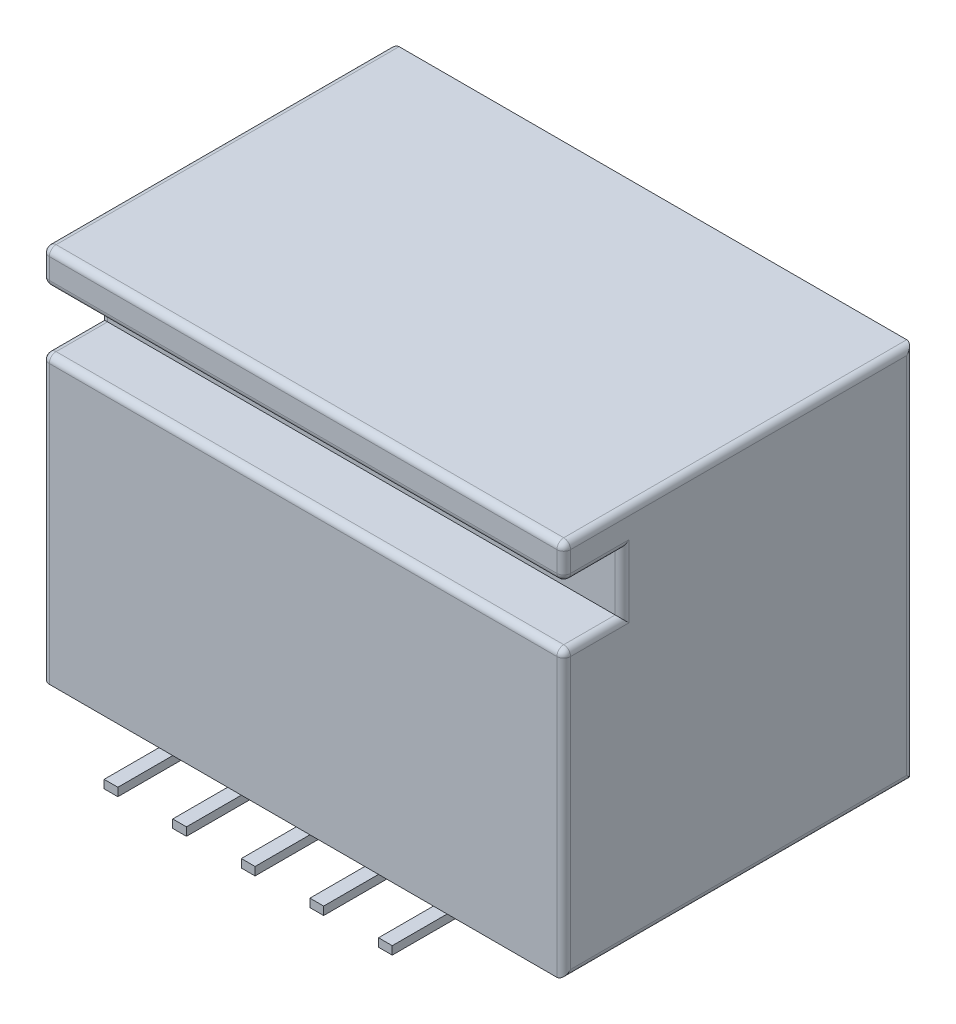
from build123d import *

# Parameters (mm, degrees)
EXTRUDE_1_DEPTH = 7.6
SHELL_1_T       = -0.3
SKETCH_2_W      = 0.2
SKETCH_2_H      = 1
EXTRUDE_2_DEPTH = 0.12
SKETCH_3_R      = 0.15
EXTRUDE_3_DEPTH = 4
FILLET_2_R      = 0.1


with BuildPart() as part:
    # 草图1 → 凸台-拉伸1 (new body)
    with BuildSketch(Plane(origin=(0, 0, 0), x_dir=(0, 0, -1), z_dir=(1, 0, 0))):
        Polygon((0, 0), (5.1, 0), (5.1, 5.5), (0, 5.5), (0, 5), (0.85, 5), (0.85, 4.15), (0, 4.15), align=None)
    extrude(amount=EXTRUDE_1_DEPTH)

    # 抽壳1
    shell_1_openings = [part.faces().sort_by_distance(p)[0] for p in [
        (3.8, 2.75, -5.1),
    ]]
    offset(amount=SHELL_1_T, openings=shell_1_openings, kind=Kind.INTERSECTION)

    # 草图2 → 凸台-拉伸2 (add)
    with BuildSketch(Plane.XZ):
        with Locations((2.8, -5.4)):
            Rectangle(SKETCH_2_W, SKETCH_2_H)
        with Locations((1.8, -5.4)):
            Rectangle(SKETCH_2_W, SKETCH_2_H)
        with Locations((3.8, -5.4)):
            Rectangle(SKETCH_2_W, SKETCH_2_H)
        with Locations((4.8, -5.4)):
            Rectangle(SKETCH_2_W, SKETCH_2_H)
        with Locations((5.8, -5.4)):
            Rectangle(SKETCH_2_W, SKETCH_2_H)
        with Locations((5.8, 0.3)):
            Rectangle(SKETCH_2_W, SKETCH_2_H)
        with Locations((4.8, 0.3)):
            Rectangle(SKETCH_2_W, SKETCH_2_H)
        with Locations((3.8, 0.3)):
            Rectangle(SKETCH_2_W, SKETCH_2_H)
        with Locations((2.8, 0.3)):
            Rectangle(SKETCH_2_W, SKETCH_2_H)
        with Locations((1.8, 0.3)):
            Rectangle(SKETCH_2_W, SKETCH_2_H)
    extrude(amount=EXTRUDE_2_DEPTH)

    # 草图3 → 凸台-拉伸3 (add)
    with BuildSketch(Plane(origin=(0, 0, -0.3), x_dir=(-1, 0, 0), z_dir=(0, 0, -1))):
        with Locations((-5.8, 1.4)):
            Circle(SKETCH_3_R)
        with Locations((-4.8, 1.4)):
            Circle(SKETCH_3_R)
        with Locations((-3.8, 1.4)):
            Circle(SKETCH_3_R)
        with Locations((-2.8, 1.4)):
            Circle(SKETCH_3_R)
        with Locations((-1.8, 1.4)):
            Circle(SKETCH_3_R)
        with Locations((-1.8, 2.8)):
            Circle(SKETCH_3_R)
        with Locations((-2.8, 2.8)):
            Circle(SKETCH_3_R)
        with Locations((-3.8, 2.8)):
            Circle(SKETCH_3_R)
        with Locations((-4.8, 2.8)):
            Circle(SKETCH_3_R)
        with Locations((-5.8, 2.8)):
            Circle(SKETCH_3_R)
    extrude(amount=EXTRUDE_3_DEPTH)

    # 圆角2
    fillet_2_edges = [part.edges().sort_by_distance(p)[0] for p in [
        (0, 5.5, -2.55),
        (0, 2.75, -5.1),
        (0, 2.075, 0),
        (7.6, 2.75, -5.1),
        (3.8, 4.15, 0),
        (3.8, 5, 0),
        (3.8, 5.5, 0),
        (7.6, 5.5, -2.55),
        (7.6, 5.25, 0),
        (7.6, 5, -0.425),
        (7.6, 4.575, -0.85),
        (7.6, 4.15, -0.425),
        (7.6, 2.075, 0),
        (0, 4.15, -0.425),
        (7.6, 0, -2.55),
        (0, 4.575, -0.85),
        (0, 5, -0.425),
        (0, 5.25, 0),
    ]]
    fillet(fillet_2_edges, radius=FILLET_2_R)


solid = part.part
